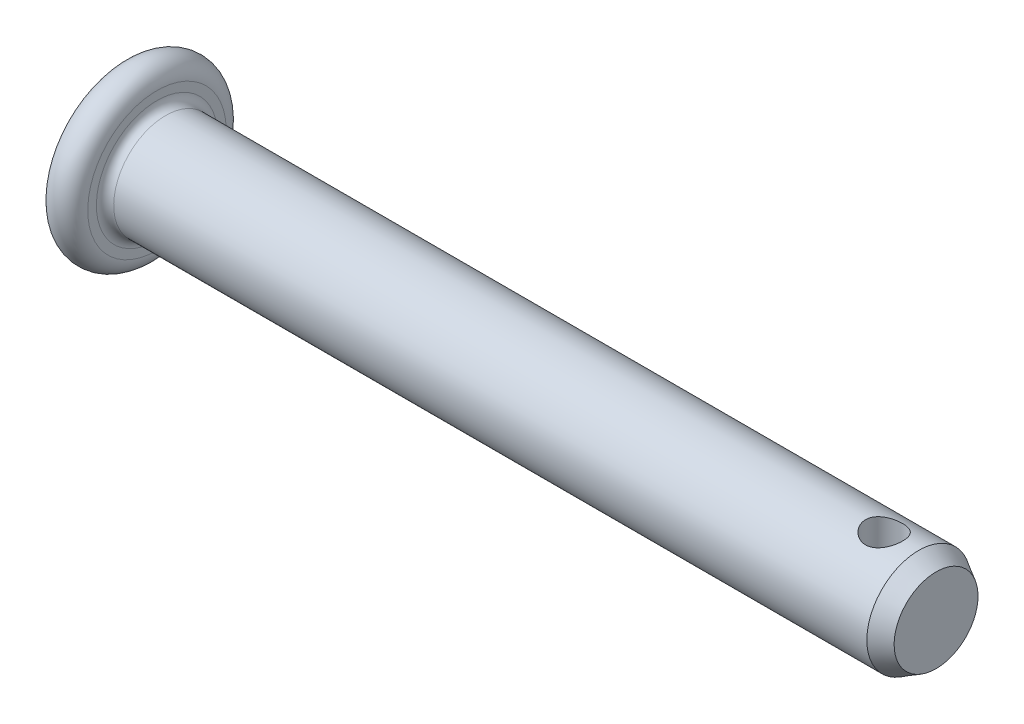
from build123d import *

# Parameters (mm, degrees)
CHAMFER1_R      = 0.5
SKETCH2_R       = 1.07
HOLE_DEPTH      = 6
HOLE_DEPTH_BACK = 6.0000001


with BuildPart() as part:
    # Sketch1 → BaseBody (revolve)
    with BuildSketch(Plane.XY):
        with BuildLine():
            Line((47, 0), (0, 0))
            Line((0, 0), (0, 4))
            ThreePointArc((0, 4), (1, 5), (2, 4))
            Line((2, 4), (2, 3))
            Line((2, 3), (46, 3))
            Line((46, 3), (47, 2.422649731))
            Line((47, 2.422649731), (47, 0))
        make_face()
    revolve(axis=Axis((-19.830028721, 0, 0), (1, 0, 0)))

    # Chamfer1
    chamfer1_edges = [part.edges().sort_by_distance(p)[0] for p in [
        (2, -3, 0),
    ]]
    fillet(chamfer1_edges, radius=CHAMFER1_R)

    # Sketch2 → Hole (cut, two sides)
    with BuildSketch(Plane(origin=(0, 0, 0), x_dir=(1, 0, 0), z_dir=(0, 1, 0))) as hole_sk:
        with Locations((44, 0)):
            Circle(SKETCH2_R)
    extrude(amount=HOLE_DEPTH, mode=Mode.SUBTRACT)
    extrude(hole_sk.sketch, amount=-HOLE_DEPTH_BACK, mode=Mode.SUBTRACT)


solid = part.part
